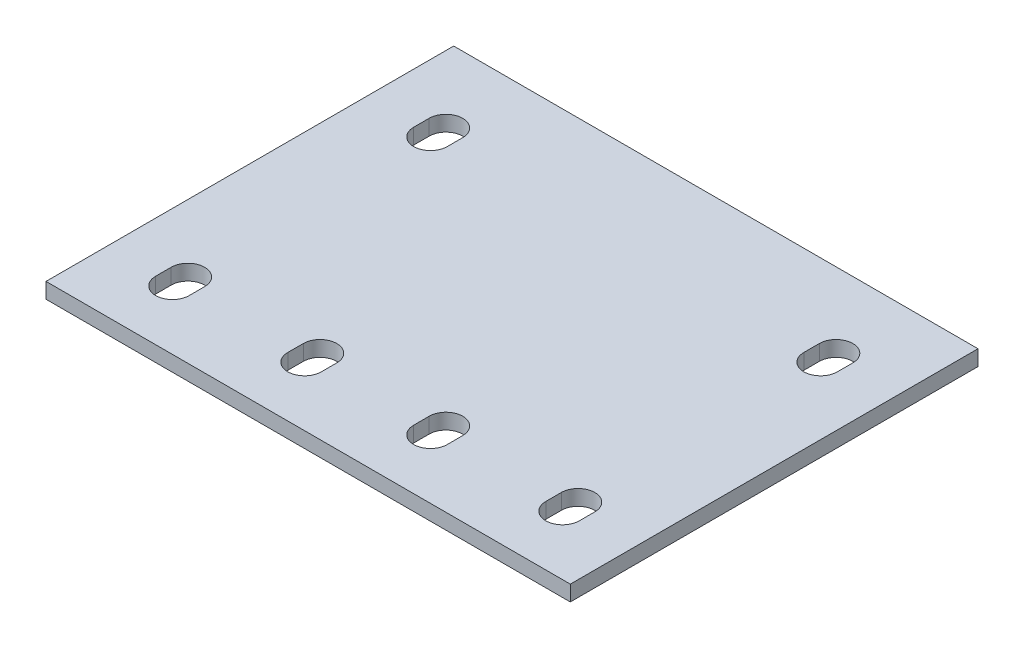
from build123d import *

# Parameters (mm, degrees)
SKETCH1_W           = 101.6
SKETCH1_H           = 79
BOSS_EXTRUDE1_DEPTH = 3


with BuildPart() as part:
    # Sketch1 → Boss-Extrude1 (new body)
    with BuildSketch(Plane(origin=(0, 0, 0), x_dir=(1, 0, 0), z_dir=(0, 1, 0))):
        with Locations((44.42740929, 26.5)):
            Rectangle(SKETCH1_W, SKETCH1_H)
        with BuildLine():
            Line((9.87740929, 51.5), (9.87740929, 48.5))
            ThreePointArc((9.87740929, 48.5), (6.62740929, 45.25), (3.37740929, 48.5))
            Line((3.37740929, 48.5), (3.37740929, 51.5))
            ThreePointArc((3.37740929, 51.5), (6.62740929, 54.75), (9.87740929, 51.5))
        make_face(mode=Mode.SUBTRACT)
        with BuildLine():
            Line((9.87740929, 1.5), (9.87740929, -1.5))
            ThreePointArc((9.87740929, -1.5), (6.62740929, -4.75), (3.37740929, -1.5))
            Line((3.37740929, -1.5), (3.37740929, 1.5))
            ThreePointArc((3.37740929, 1.5), (6.62740929, 4.75), (9.87740929, 1.5))
        make_face(mode=Mode.SUBTRACT)
        with BuildLine():
            Line((59.87740929, 1.5), (59.87740929, -1.5))
            ThreePointArc((59.87740929, -1.5), (56.62740929, -4.75), (53.37740929, -1.5))
            Line((53.37740929, -1.5), (53.37740929, 1.5))
            ThreePointArc((53.37740929, 1.5), (56.62740929, 4.75), (59.87740929, 1.5))
        make_face(mode=Mode.SUBTRACT)
        with BuildLine():
            Line((85.47740929, 51.5), (85.47740929, 48.5))
            ThreePointArc((85.47740929, 48.5), (82.22740929, 45.25), (78.97740929, 48.5))
            Line((78.97740929, 48.5), (78.97740929, 51.5))
            ThreePointArc((78.97740929, 51.5), (82.22740929, 54.75), (85.47740929, 51.5))
        make_face(mode=Mode.SUBTRACT)
        with BuildLine():
            Line((78.97740929, 1.5), (78.97740929, -1.5))
            ThreePointArc((78.97740929, -1.5), (82.22740929, -4.75), (85.47740929, -1.5))
            Line((85.47740929, -1.5), (85.47740929, 1.5))
            ThreePointArc((85.47740929, 1.5), (82.22740929, 4.75), (78.97740929, 1.5))
        make_face(mode=Mode.SUBTRACT)
        with BuildLine():
            Line((28.97740929, 1.5), (28.97740929, -1.5))
            ThreePointArc((28.97740929, -1.5), (32.22740929, -4.75), (35.47740929, -1.5))
            Line((35.47740929, -1.5), (35.47740929, 1.5))
            ThreePointArc((35.47740929, 1.5), (32.22740929, 4.75), (28.97740929, 1.5))
        make_face(mode=Mode.SUBTRACT)
    extrude(amount=BOSS_EXTRUDE1_DEPTH)


solid = part.part
